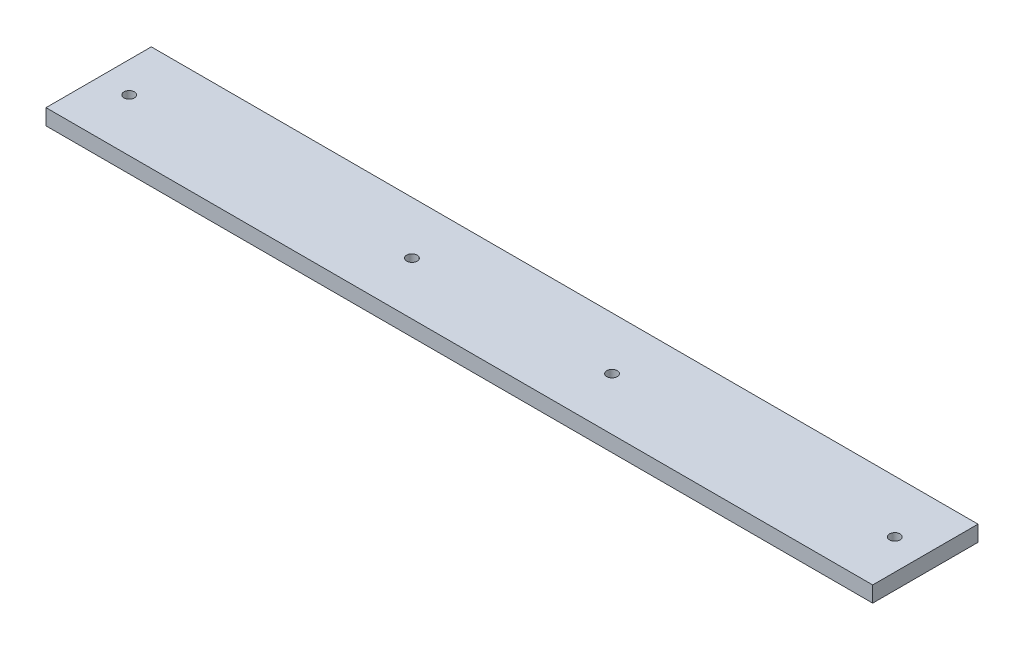
from build123d import *

# Parameters (mm, degrees)
CROQUIS1_W              = 785
CROQUIS1_H              = 100
SALIENTE_EXTRUIR1_DEPTH = 15
CROQUIS5_R              = 5
CORTAR_EXTRUIR4_DEPTH   = 16
CROQUIS6_R              = 5
CORTAR_EXTRUIR5_DEPTH   = 16


with BuildPart() as part:
    # Croquis1 → Saliente-Extruir1 (new body)
    with BuildSketch(Plane(origin=(0, 0, 0), x_dir=(1, 0, 0), z_dir=(0, 1, 0))):
        with Locations((353.936588921, -42.333090379)):
            Rectangle(CROQUIS1_W, CROQUIS1_H)
    extrude(amount=-SALIENTE_EXTRUIR1_DEPTH)

    # Croquis5 → Cortar-Extruir4 (cut, through all)
    with BuildSketch(Plane(origin=(0, 0, 0), x_dir=(1, 0, 0), z_dir=(0, 1, 0))):
        with Locations((258.936588921, -42.333090379)):
            Circle(CROQUIS5_R)
        with Locations((448.936588921, -42.333090379)):
            Circle(CROQUIS5_R)
    extrude(amount=-CORTAR_EXTRUIR4_DEPTH, mode=Mode.SUBTRACT)

    # Croquis6 → Cortar-Extruir5 (cut, through all)
    with BuildSketch(Plane(origin=(0, 0, 0), x_dir=(1, 0, 0), z_dir=(0, 1, 0))):
        with Locations((-9.563411079, -42.333090379)):
            Circle(CROQUIS6_R)
        with Locations((717.436588921, -42.333090379)):
            Circle(CROQUIS6_R)
    extrude(amount=-CORTAR_EXTRUIR5_DEPTH, mode=Mode.SUBTRACT)


solid = part.part
